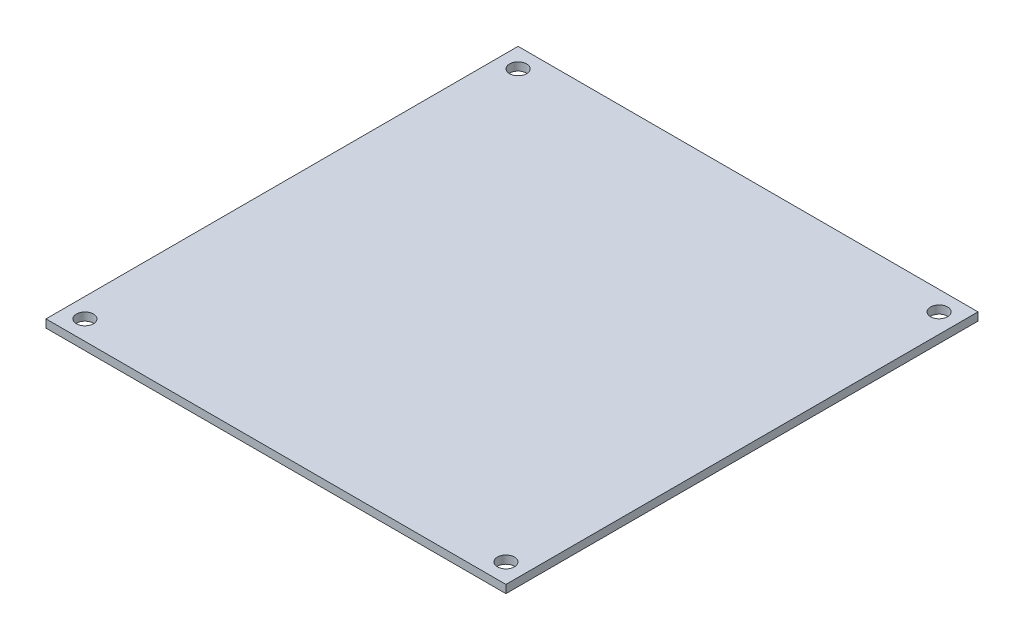
from build123d import *

# Parameters (mm, degrees)
SKETCH1_W           = 94.5
SKETCH1_H           = 97
BOSS_EXTRUDE1_DEPTH = 1.65
SKETCH2_R           = 1.75
CUT_EXTRUDE1_DEPTH  = 2.65


with BuildPart() as part:
    # Sketch1 → Boss-Extrude1 (new body)
    with BuildSketch(Plane(origin=(0, 0, 0), x_dir=(1, 0, 0), z_dir=(0, 1, 0))):
        with Locations((47.25, 48.5)):
            Rectangle(SKETCH1_W, SKETCH1_H)
    extrude(amount=BOSS_EXTRUDE1_DEPTH)

    # Sketch2 → Cut-Extrude1 (cut, through all)
    with BuildSketch(Plane(origin=(0, 1.65, 0), x_dir=(1, 0, 0), z_dir=(0, 1, 0))):
        with Locations((4, 93)):
            Circle(SKETCH2_R)
        with Locations((90.5, 93)):
            Circle(SKETCH2_R)
        with Locations((90.5, 4)):
            Circle(SKETCH2_R)
        with Locations((4, 4)):
            Circle(SKETCH2_R)
    extrude(amount=-CUT_EXTRUDE1_DEPTH, mode=Mode.SUBTRACT)


solid = part.part
